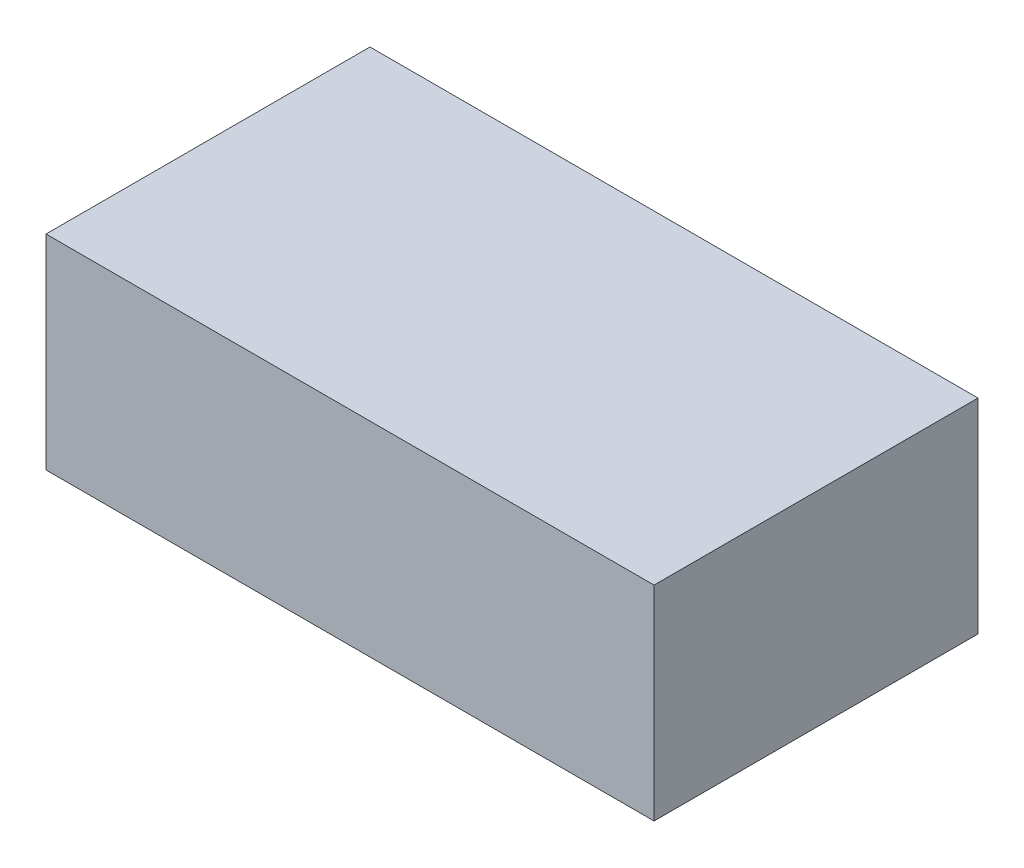
from build123d import *

# Parameters (mm, degrees)
SKETCH_1_W      = 122
SKETCH_1_H      = 65
EXTRUDE_1_DEPTH = 41


with BuildPart() as part:
    # 草圖1 → 填料-伸長1 (new body)
    with BuildSketch(Plane(origin=(0, 0, 0), x_dir=(1, 0, 0), z_dir=(0, 1, 0))):
        Rectangle(SKETCH_1_W, SKETCH_1_H)
    extrude(amount=EXTRUDE_1_DEPTH)


solid = part.part
